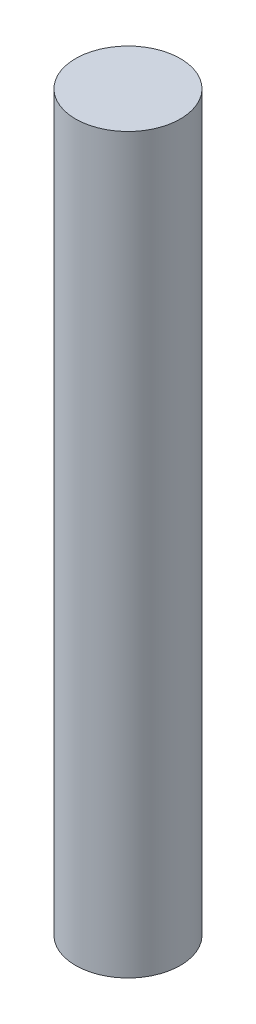
from build123d import *

# Parameters (mm, degrees)
SKETCH1_R           = 0.635
BOSS_EXTRUDE1_DEPTH = 4.445


with BuildPart() as part:
    # Sketch1 → Boss-Extrude1 (new body, symmetric)
    with BuildSketch(Plane(origin=(0, 0, 0), x_dir=(1, 0, 0), z_dir=(0, 1, 0))):
        Circle(SKETCH1_R)
    extrude(amount=BOSS_EXTRUDE1_DEPTH, both=True)


solid = part.part
